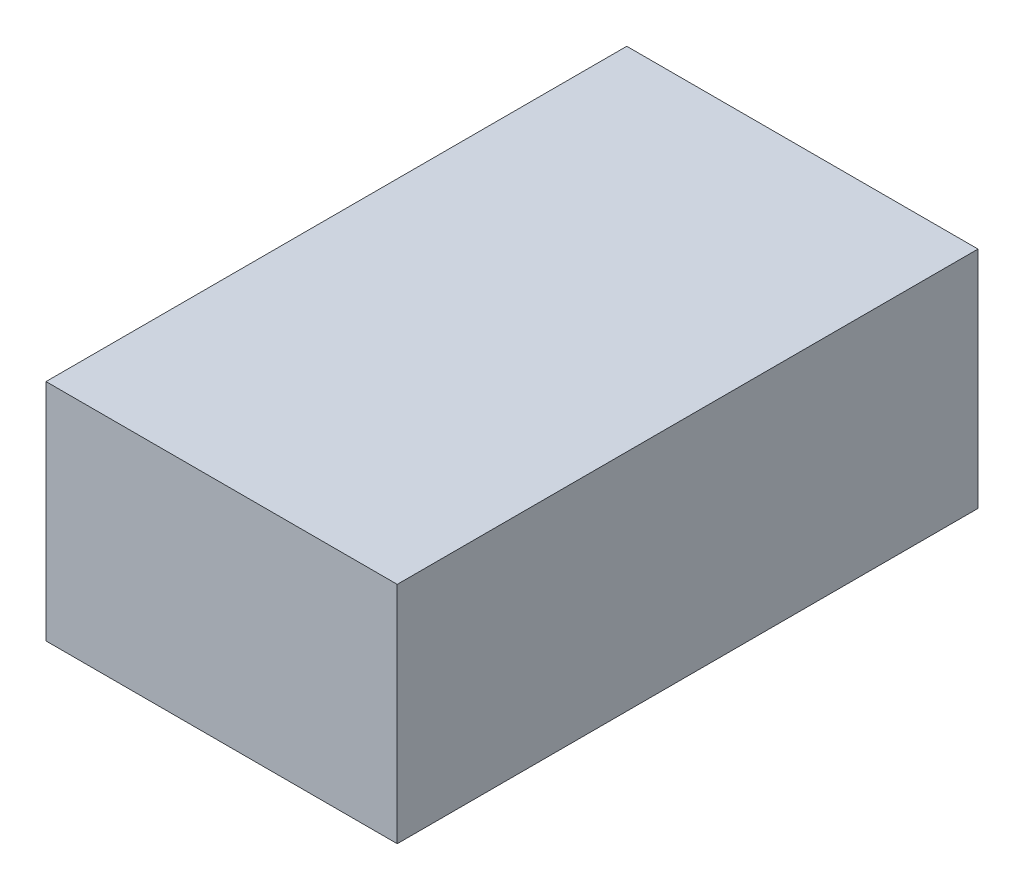
from build123d import *

# Parameters (mm, degrees)
SKETCH1_W           = 320.53572501
SKETCH1_H           = 205.006558649
BOSS_EXTRUDE1_DEPTH = 530
SKETCH2_W           = 260.54
SKETCH2_H           = 470
CUT_EXTRUDE1_DEPTH  = 30


with BuildPart() as part:
    # Sketch1 → Boss-Extrude1 (new body)
    with BuildSketch(Plane.XY.offset(30)):
        with Locations((0, -2.496720675)):
            Rectangle(SKETCH1_W, SKETCH1_H)
    extrude(amount=-BOSS_EXTRUDE1_DEPTH)

    # Sketch2 → Cut-Extrude1 (cut)
    with BuildSketch(Plane.XZ.offset(105)):
        with Locations((0.002137495, -235)):
            Rectangle(SKETCH2_W, SKETCH2_H)
    extrude(amount=-CUT_EXTRUDE1_DEPTH, mode=Mode.SUBTRACT)


solid = part.part
